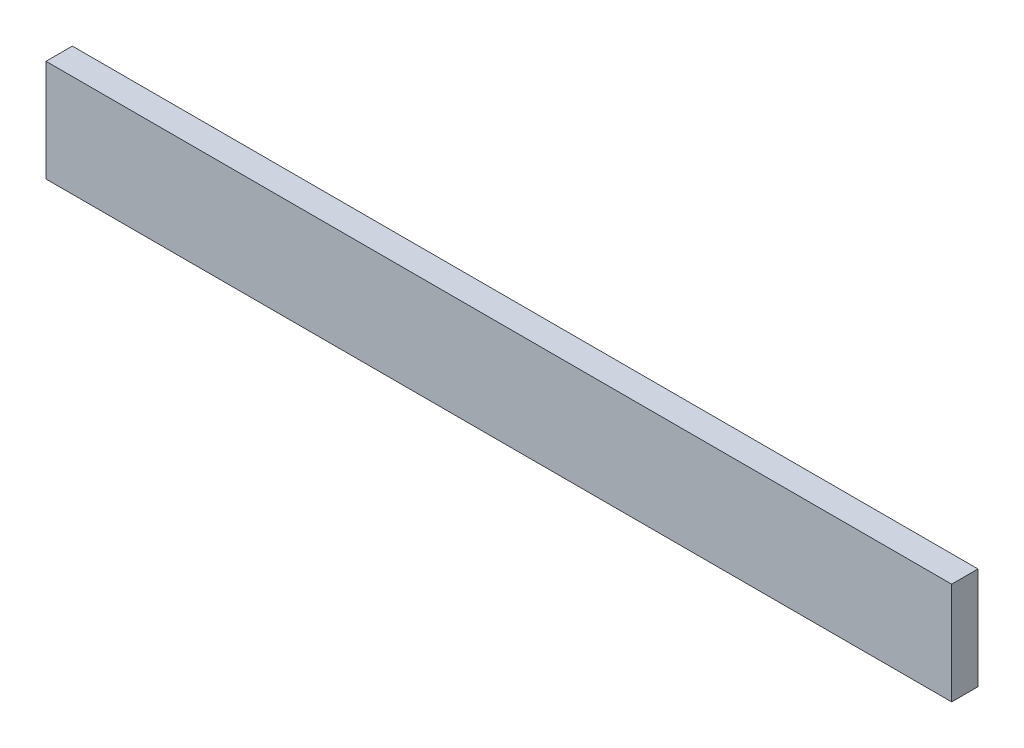
from build123d import *

# Parameters (mm, degrees)
SKETCH1_W           = 550
SKETCH1_H           = 61.94
BOSS_EXTRUDE1_DEPTH = 16


with BuildPart() as part:
    # Sketch1 → Boss-Extrude1 (new body)
    with BuildSketch(Plane.XY):
        Rectangle(SKETCH1_W, SKETCH1_H)
    extrude(amount=BOSS_EXTRUDE1_DEPTH)


solid = part.part
